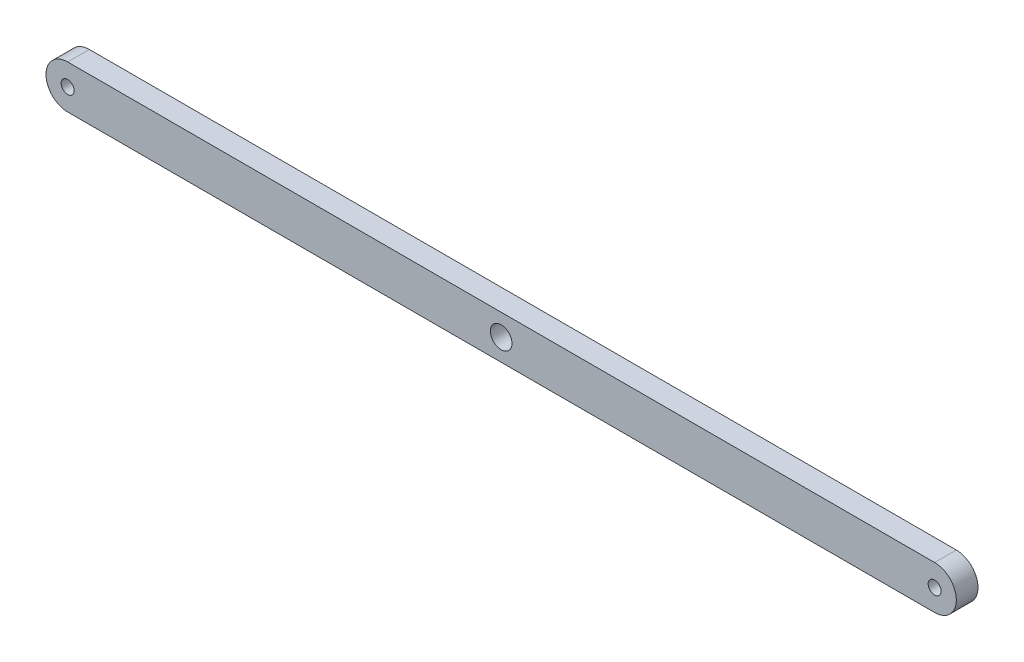
from build123d import *

# Parameters (mm, degrees)
BOSS_EXTRUDE1_DEPTH     = 25
SKETCH2_R               = 15
CUT_EXTRUDE1_DEPTH      = 1053.378258992
CUT_EXTRUDE2_DEPTH      = 1052.487042241
CUT_EXTRUDE2_DEPTH_BACK = 1052.487042241
SKETCH3_R               = 25


with BuildPart() as part:
    # Sketch1 → Boss-Extrude1 (new, symmetric)
    with BuildSketch(Plane.XY):
        with BuildLine():
            Line((-1000, 50), (1000, 50))
            ThreePointArc((1000, 50), (1050, 0), (1000, -50))
            Line((1000, -50), (-1000, -50))
            ThreePointArc((-1000, -50), (-1050, 0), (-1000, 50))
        make_face()
    extrude(amount=BOSS_EXTRUDE1_DEPTH, both=True)

    # Sketch2 → Cut-Extrude1 (cut, through all)
    with BuildSketch(Plane.XY.offset(25)):
        with Locations((-1000, 0)):
            Circle(SKETCH2_R)
        with Locations((1000, 0)):
            Circle(SKETCH2_R)
    extrude(amount=-CUT_EXTRUDE1_DEPTH, mode=Mode.SUBTRACT)

    # Sketch3 → Cut-Extrude2 (cut, two sides: drawn at the far end of the back side and taken through both)
    with BuildSketch(Plane.XY.offset(-CUT_EXTRUDE2_DEPTH_BACK)):
        Circle(SKETCH3_R)
    extrude(amount=CUT_EXTRUDE2_DEPTH + CUT_EXTRUDE2_DEPTH_BACK, mode=Mode.SUBTRACT)


solid = part.part
